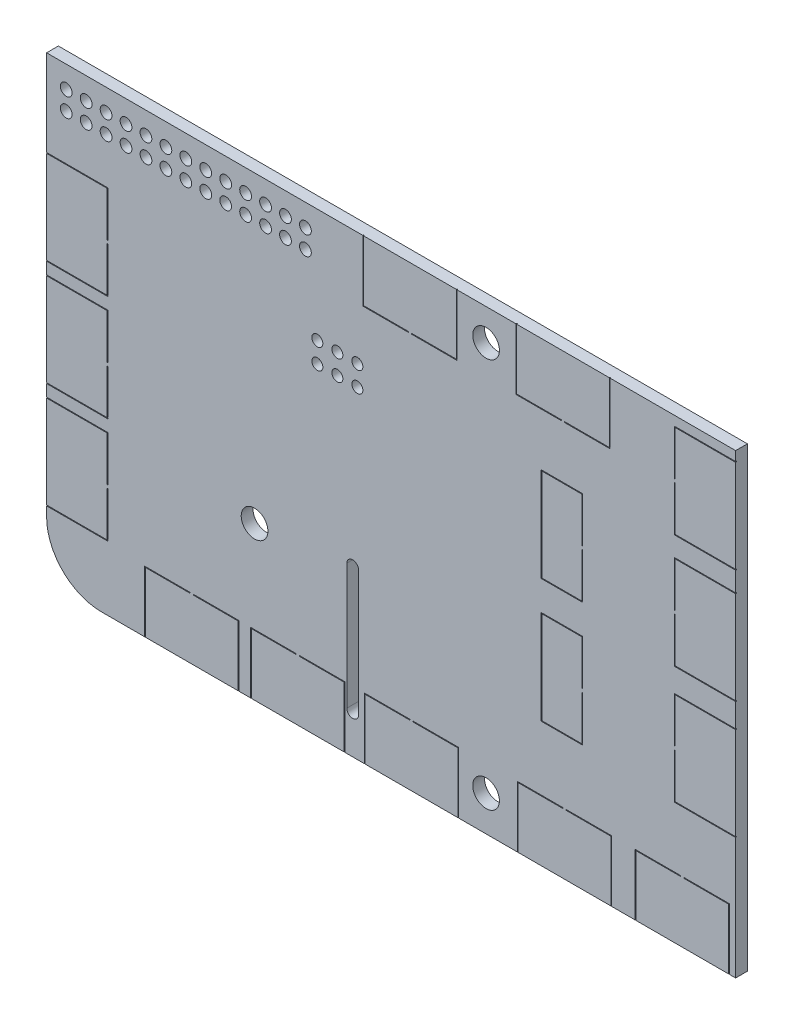
from build123d import *

# Parameters (mm, degrees)
ESQUISSE1_R                = 1.7
BOSS_EXTRU_1_DEPTH         = 1.5
ESQUISSE2_R                = 0.75
ENL_V_MAT_EXTRU_3_DEPTH    = 2.5
R_P_TITION_LIN_AIRE1_COUNT = 13
R_P_TITION_LIN_AIRE1_PITCH = 2.54
ESQUISSE3_R                = 0.7
ENL_V_MAT_EXTRU_4_DEPTH    = 1.5
R_P_TITION_LIN_AIRE2_COUNT = 3
R_P_TITION_LIN_AIRE2_PITCH = 2.55
ENL_V_MAT_EXTRU_8_DEPTH    = 0.1


with BuildPart() as part:
    # Esquisse1 → Boss.-Extru.1 (new body)
    with BuildSketch(Plane.XY):
        with BuildLine():
            Line((-36.9, -29.1), (43.9, -29.1))
            Line((43.9, -29.1), (43.9, 29.1))
            Line((43.9, 29.1), (-43.9, 29.1))
            Line((-43.9, 29.1), (-43.9, -22.1))
            ThreePointArc((-43.9, -22.1), (-41.849747468, -27.049747468), (-36.9, -29.1))
        make_face()
        with Locations((12.1, 25.1)):
            Circle(ESQUISSE1_R, mode=Mode.SUBTRACT)
        with Locations((-17.4, -9.6)):
            Circle(ESQUISSE1_R, mode=Mode.SUBTRACT)
        with Locations((12.1, -24.6)):
            Circle(ESQUISSE1_R, mode=Mode.SUBTRACT)
        with BuildLine():
            Line((-4.15, -8.1), (-4.15, -24.1))
            ThreePointArc((-4.15, -24.1), (-4.9, -24.85), (-5.65, -24.1))
            Line((-5.65, -24.1), (-5.65, -8.1))
            ThreePointArc((-5.65, -8.1), (-4.9, -7.35), (-4.15, -8.1))
        make_face(mode=Mode.SUBTRACT)
    extrude(amount=BOSS_EXTRU_1_DEPTH)

    # Esquisse2 → Enlèv. mat.-Extru.3 (cut, through all)
    with BuildSketch(Plane.XY):
        with Locations((-41.4, 26.3)):
            Circle(ESQUISSE2_R)
        with Locations((-41.4, 23.9)):
            Circle(ESQUISSE2_R)
    enl_v_mat_extru_3 = extrude(amount=ENL_V_MAT_EXTRU_3_DEPTH, mode=Mode.SUBTRACT)

    # Répétition linéaire1: Enlèv. mat.-Extru.3 ×13
    with Locations(*[(i * R_P_TITION_LIN_AIRE1_PITCH, 0, 0) for i in range(1, R_P_TITION_LIN_AIRE1_COUNT)]):
        add(enl_v_mat_extru_3, mode=Mode.SUBTRACT)

    # Esquisse3 → Enlèv. mat.-Extru.4 (cut)
    with BuildSketch(Plane.XY.offset(1.5)):
        with Locations((-9.4, 14.6)):
            Circle(ESQUISSE3_R)
        with Locations((-9.4, 12)):
            Circle(ESQUISSE3_R)
    enl_v_mat_extru_4 = extrude(amount=-ENL_V_MAT_EXTRU_4_DEPTH, mode=Mode.SUBTRACT)

    # Répétition linéaire2: Enlèv. mat.-Extru.4 ×3
    with Locations(*[(i * R_P_TITION_LIN_AIRE2_PITCH, 0, 0) for i in range(1, R_P_TITION_LIN_AIRE2_COUNT)]):
        add(enl_v_mat_extru_4, mode=Mode.SUBTRACT)

    # Esquisse5 → Enlèv. mat.-Extru.8 (cut)
    with BuildSketch(Plane.XY.offset(1.5)):
        Polygon((-46, 18), (-36.2, 18), (-36.2, 12.3), (-36.1, 12.3), (-36.1, 18.1), (-46.1, 18.1), (-46.1, 6.1), (-36.1, 6.1), (-36.1, 11.9), (-36.2, 11.9), (-36.2, 6.2), (-46, 6.2), align=None)
        Polygon((-46, 4.5), (-36.2, 4.5), (-36.2, -1.2), (-36.1, -1.2), (-36.1, 4.6), (-46.1, 4.6), (-46.1, -7.4), (-36.1, -7.4), (-36.1, -1.6), (-36.2, -1.6), (-36.2, -7.3), (-46, -7.3), align=None)
        Polygon((-46, -9), (-36.2, -9), (-36.2, -14.7), (-36.1, -14.7), (-36.1, -8.9), (-46.1, -8.9), (-46.1, -20.9), (-36.1, -20.9), (-36.1, -15.1), (-36.2, -15.1), (-36.2, -20.8), (-46, -20.8), align=None)
        Polygon((-3.4, -21.3), (2.4, -21.3), (2.4, -21.4), (-3.3, -21.4), (-3.3, -31.2), (8.5, -31.2), (8.5, -21.4), (2.8, -21.4), (2.8, -21.3), (8.6, -21.3), (8.6, -31.3), (-3.4, -31.3), align=None)
        Polygon((-31.4, -21.3), (-25.6, -21.3), (-25.6, -21.4), (-31.3, -21.4), (-31.3, -31.2), (-19.5, -31.2), (-19.5, -21.4), (-25.2, -21.4), (-25.2, -21.3), (-19.4, -21.3), (-19.4, -31.3), (-31.4, -31.3), align=None)
        Polygon((-17.9, -21.3), (-12.1, -21.3), (-12.1, -21.4), (-17.8, -21.4), (-17.8, -31.2), (-6, -31.2), (-6, -21.4), (-11.7, -21.4), (-11.7, -21.3), (-5.9, -21.3), (-5.9, -31.3), (-17.9, -31.3), align=None)
        Polygon((16.1, -21.3), (21.9, -21.3), (21.9, -21.4), (16.2, -21.4), (16.2, -31.2), (28, -31.2), (28, -21.4), (22.3, -21.4), (22.3, -21.3), (28.1, -21.3), (28.1, -31.3), (16.1, -31.3), align=None)
        Polygon((31.1, -21.3), (36.9, -21.3), (36.9, -21.4), (31.2, -21.4), (31.2, -31.2), (43, -31.2), (43, -21.4), (37.3, -21.4), (37.3, -21.3), (43.1, -21.3), (43.1, -31.3), (31.1, -31.3), align=None)
        Polygon((36.1, -7.4), (36.2, -7.4), (36.2, -1.7), (46, -1.7), (46, -13.5), (36.2, -13.5), (36.2, -7.8), (36.1, -7.8), (36.1, -13.6), (46.1, -13.6), (46.1, -1.6), (36.1, -1.6), align=None)
        Polygon((36.1, 7.6), (36.2, 7.6), (36.2, 13.3), (46, 13.3), (46, 1.5), (36.2, 1.5), (36.2, 7.2), (36.1, 7.2), (36.1, 1.4), (46.1, 1.4), (46.1, 13.4), (36.1, 13.4), align=None)
        Polygon((36.1, 22.1), (36.2, 22.1), (36.2, 27.8), (46, 27.8), (46, 16), (36.2, 16), (36.2, 21.7), (36.1, 21.7), (36.1, 15.9), (46.1, 15.9), (46.1, 27.9), (36.1, 27.9), align=None)
        Polygon((15.9, 21.3), (21.7, 21.3), (21.7, 21.4), (16, 21.4), (16, 31.2), (27.8, 31.2), (27.8, 21.4), (22.1, 21.4), (22.1, 21.3), (27.9, 21.3), (27.9, 31.3), (15.9, 31.3), align=None)
        Polygon((-3.6, 21.3), (2.2, 21.3), (2.2, 21.4), (-3.5, 21.4), (-3.5, 31.2), (8.3, 31.2), (8.3, 21.4), (2.6, 21.4), (2.6, 21.3), (8.4, 21.3), (8.4, 31.3), (-3.6, 31.3), align=None)
        Polygon((24.4, 14.6), (24.4, 8.8), (24.3, 8.8), (24.3, 14.5), (19.2, 14.5), (19.2, 2.7), (24.3, 2.7), (24.3, 8.4), (24.4, 8.4), (24.4, 2.6), (19.1, 2.6), (19.1, 14.6), align=None)
        Polygon((24.4, -1.15), (24.4, -6.95), (24.3, -6.95), (24.3, -1.25), (19.2, -1.25), (19.2, -13.05), (24.3, -13.05), (24.3, -7.35), (24.4, -7.35), (24.4, -13.15), (19.1, -13.15), (19.1, -1.15), align=None)
    extrude(amount=-ENL_V_MAT_EXTRU_8_DEPTH, mode=Mode.SUBTRACT)


solid = part.part
